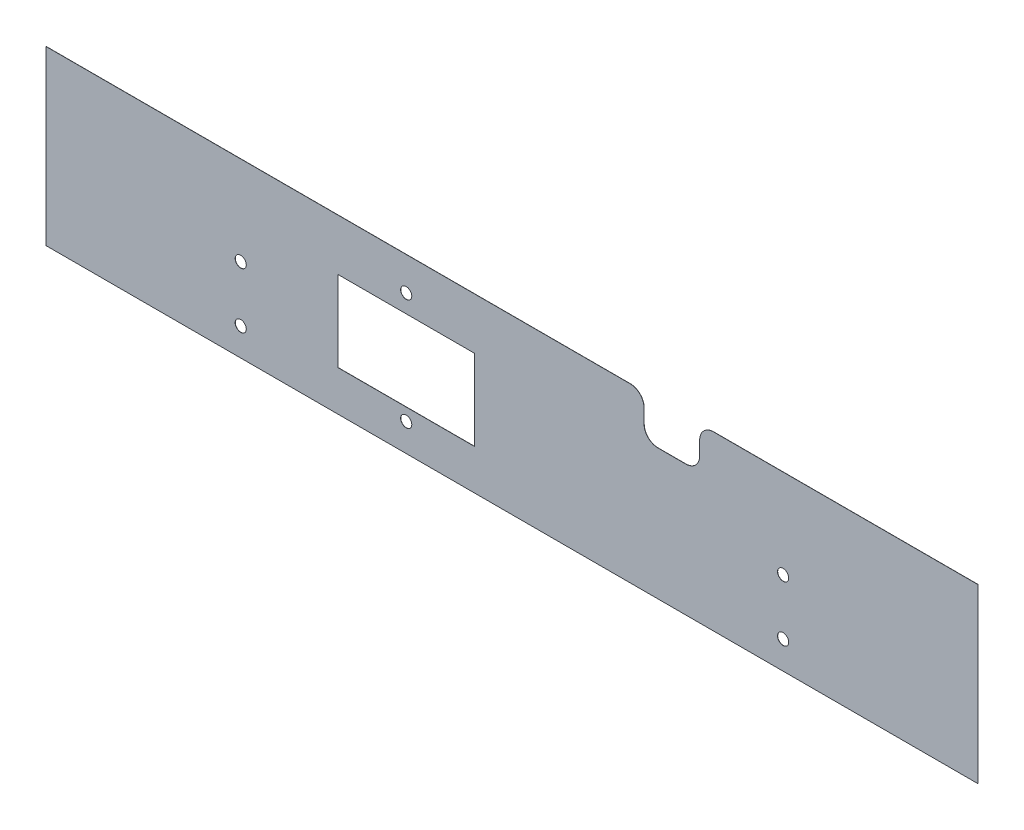
from build123d import *

# Parameters (mm, degrees)
SKETCH1_W            = 335
SKETCH1_H            = 62
BODY_DEPTH           = 0.0625
SKETCH3_R            = 2
MOUNTING_HOLES_DEPTH = 0.0625
SKETCH4_R            = 2
SKETCH4_W            = 49
SKETCH4_H            = 29
SKETCH4_W_2          = 20
SKETCH4_H_2          = 15
CUT_EXTRUDE1_DEPTH   = 10
FILLET1_R            = 5


with BuildPart() as part:
    # Sketch1 → Body (new body)
    with BuildSketch(Plane.XY):
        Rectangle(SKETCH1_W, SKETCH1_H)
    extrude(amount=BODY_DEPTH)

    # Sketch3 → Mounting Holes (cut)
    with BuildSketch(Plane.XY.offset(0.0625)):
        with Locations((-97.5, -1)):
            Circle(SKETCH3_R)
        with Locations((-97.5, -21)):
            Circle(SKETCH3_R)
        with Locations((97.5, -1)):
            Circle(SKETCH3_R)
        with Locations((97.5, -21)):
            Circle(SKETCH3_R)
    extrude(amount=-MOUNTING_HOLES_DEPTH, mode=Mode.SUBTRACT)

    # Sketch4 → Cut-Extrude1 (cut)
    with BuildSketch(Plane.XY.offset(0.0625)):
        with Locations((-38, 19)):
            Circle(SKETCH4_R)
        with Locations((-38, -21)):
            Circle(SKETCH4_R)
        with Locations((-38, -2)):
            Rectangle(SKETCH4_W, SKETCH4_H)
        with Locations((57.5, 23.5)):
            Rectangle(SKETCH4_W_2, SKETCH4_H_2)
    extrude(amount=-CUT_EXTRUDE1_DEPTH, mode=Mode.SUBTRACT)

    # Fillet1
    fillet1_edges = [part.edges().sort_by_distance(p)[0] for p in [
        (47.5, 16, 0.03125),
        (47.5, 31, 0.03125),
        (67.5, 31, 0.03125),
        (67.5, 16, 0.03125),
    ]]
    fillet(fillet1_edges, radius=FILLET1_R)


solid = part.part
